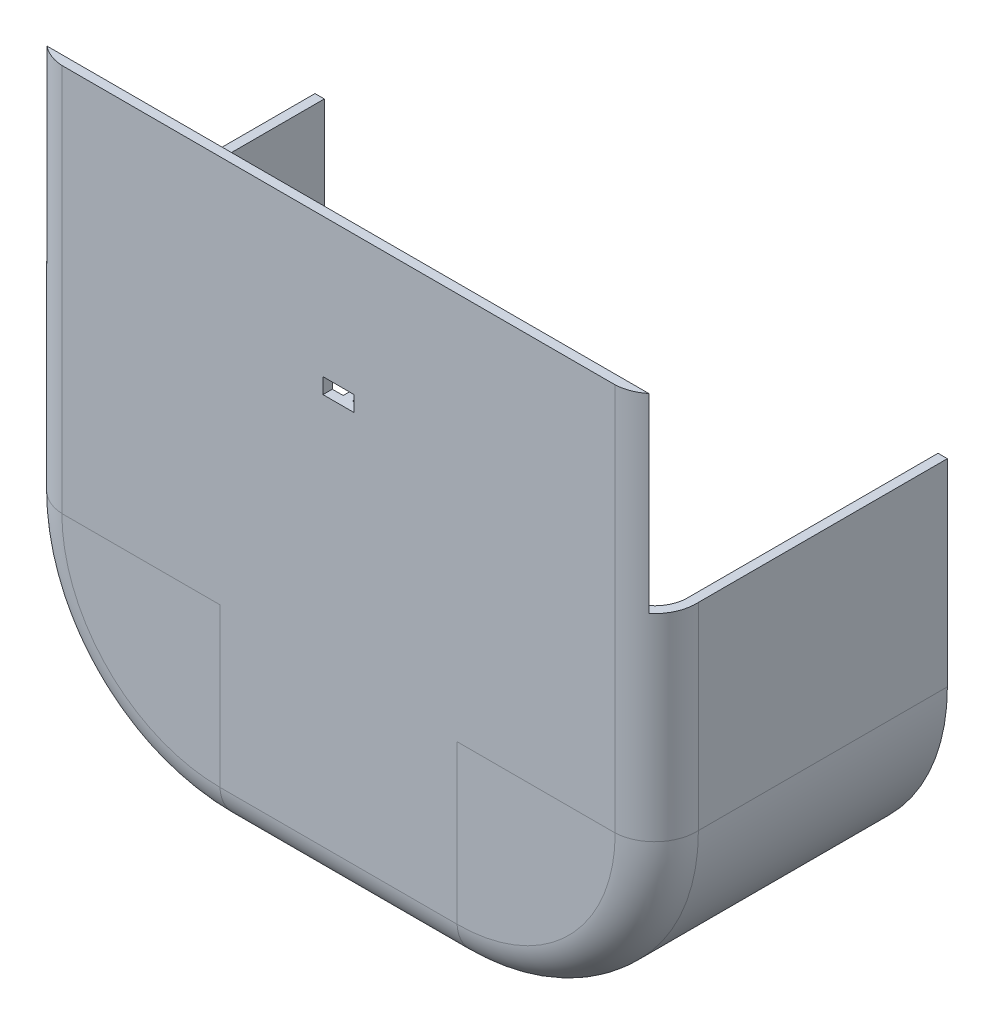
from build123d import *

# Parameters (mm, degrees)
BOSS_EXTRUDE1_DEPTH = 60
SKETCH6_W           = 76.2
SKETCH6_H           = 139.7
BOSS_EXTRUDE3_DEPTH = 3
SKETCH7_W           = 254.695348458
SKETCH7_H           = 135.329086622
CUT_EXTRUDE1_DEPTH  = 76.2
SKETCH8_W           = 10
SKETCH8_H           = 5
CUT_EXTRUDE2_DEPTH  = 95.039099262
SKETCH9_W           = 55
SKETCH9_H           = 40
CUT_EXTRUDE3_DEPTH  = 204.2
SKETCH10_W          = 200.764393162
SKETCH10_H          = 14.388440844
CUT_EXTRUDE4_DEPTH  = 15
BOSS_EXTRUDE4_DEPTH = 4
BOSS_EXTRUDE5_DEPTH = 4


with BuildPart() as part:
    # Sketch1 → Boss-Extrude1 (new body)
    with BuildSketch(Plane.XY):
        with BuildLine():
            Line((-101.6, 101.6), (-101.6, -38.1))
            ThreePointArc((-101.6, -38.1), (-83.001280605, -83.001280605), (-38.1, -101.6))
            Line((-38.1, -101.6), (38.1, -101.6))
            ThreePointArc((38.1, -101.6), (83.001280605, -83.001280605), (101.6, -38.1))
            Line((101.6, -38.1), (101.6, 101.6))
            Line((101.6, 101.6), (-101.6, 101.6))
        make_face()
        with BuildLine():
            Line((-98.6, 98.6), (-98.6, -38.1))
            ThreePointArc((-98.6, -38.1), (-80.879960262, -80.879960262), (-38.1, -98.6))
            Line((-38.1, -98.6), (38.1, -98.6))
            ThreePointArc((38.1, -98.6), (80.879960262, -80.879960262), (98.6, -38.1))
            Line((98.6, -38.1), (98.6, 98.6))
            Line((98.6, 98.6), (-98.6, 98.6))
        make_face(mode=Mode.SUBTRACT)
    extrude(amount=BOSS_EXTRUDE1_DEPTH)

    # Sweep2: sweep along a path in Sketch5
    with BuildLine(Plane.XY.offset(60)) as sweep2_path:
        Line((-100.1, 101.6), (-100.1, -38.1))
        ThreePointArc((-100.1, -38.1), (-81.940620434, -81.940620434), (-38.1, -100.1))
        Line((-38.1, -100.1), (38.1, -100.1))
        ThreePointArc((38.1, -100.1), (81.940620434, -81.940620434), (100.1, -38.1))
        Line((100.1, -38.1), (100.1, 101.6))
    # Sketch3 → Sweep2 (sweep)
    with BuildSketch(Plane(origin=(0, 101.6, 0), x_dir=(1, 0, 0), z_dir=(0, 1, 0))):
        with BuildLine():
            Line((-38.1, -91.039099262), (-88.9, -91.039099262))
            ThreePointArc((-88.9, -91.039099262), (-95.981959893, -87.480761361), (-98.6, -80))
            Line((-98.6, -80), (-98.6, -60))
            Line((-98.6, -60), (-101.6, -60))
            Line((-101.6, -60), (-101.6, -80))
            ThreePointArc((-101.6, -80), (-98.157592659, -89.649805752), (-88.9, -94.039099262))
            Line((-88.9, -94.039099262), (-38.1, -94.039099262))
            Line((-38.1, -94.039099262), (-38.1, -91.039099262))
        make_face()
    sweep(path=sweep2_path.line)

    # Sketch6 → Boss-Extrude3 (add)
    with BuildSketch(Plane.XY.offset(94.039099262)):
        with Locations((0, 31.75)):
            Rectangle(SKETCH6_W, SKETCH6_H)
    extrude(amount=-BOSS_EXTRUDE3_DEPTH)

    # Sketch7 → Cut-Extrude1 (cut)
    with BuildSketch(Plane(origin=(0, 101.6, 0), x_dir=(1, 0, 0), z_dir=(0, 1, 0))):
        with Locations((-4.889183354, -23.374555951)):
            Rectangle(SKETCH7_W, SKETCH7_H)
    extrude(amount=-CUT_EXTRUDE1_DEPTH, mode=Mode.SUBTRACT)

    # Sketch8 → Cut-Extrude2 (cut, through all)
    with BuildSketch(Plane.XY.offset(94.039099262)):
        with Locations((0, 39.440517612)):
            Rectangle(SKETCH8_W, SKETCH8_H)
    extrude(amount=-CUT_EXTRUDE2_DEPTH, mode=Mode.SUBTRACT)

    # Sketch9 → Cut-Extrude3 (cut, through all)
    with BuildSketch(Plane(origin=(0, -101.6, 0), x_dir=(-1, 0, 0), z_dir=(0, -1, 0))):
        with Locations((0, -20)):
            Rectangle(SKETCH9_W, SKETCH9_H)
    extrude(amount=-CUT_EXTRUDE3_DEPTH, mode=Mode.SUBTRACT)

    # Sketch10 → Cut-Extrude4 (cut)
    with BuildSketch(Plane(origin=(0, 101.6, 0), x_dir=(1, 0, 0), z_dir=(0, 1, 0))):
        with Locations((0, -94.039099262)):
            Rectangle(SKETCH10_W, SKETCH10_H)
    extrude(amount=-CUT_EXTRUDE4_DEPTH, mode=Mode.SUBTRACT)

    # Sketch11 → Boss-Extrude4 (add)
    with BuildSketch(Plane(origin=(0, -98.6, 0), x_dir=(1, 0, 0), z_dir=(0, 1, 0))):
        Polygon((0, -80), (1.5, -80), (1.5, -40), (0, -40), (-1.5, -40), (-1.5, -80), align=None)
    extrude(amount=BOSS_EXTRUDE4_DEPTH)

    # Sketch12 → Boss-Extrude5 (add)
    with BuildSketch(Plane(origin=(0, 0, 91.039099262), x_dir=(-1, 0, 0), z_dir=(0, 0, -1))):
        Polygon((-1.5, -88.9), (0, -88.9), (1.5, -88.9), (1.5, 36.940517612), (-1.5, 36.940517612), align=None)
    extrude(amount=BOSS_EXTRUDE5_DEPTH)


solid = part.part
